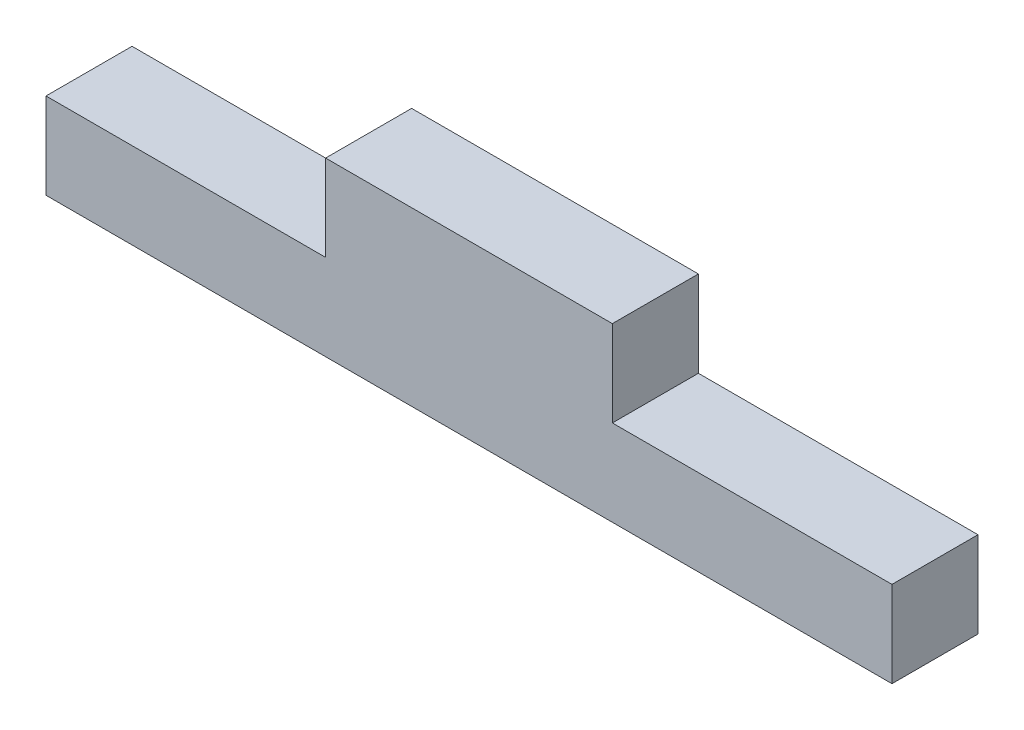
from build123d import *

# Parameters (mm, degrees)
RESSALTO_EXTRUS_O1_DEPTH = 6


with BuildPart() as part:
    # Esboço1 → Ressalto-extrusão1 (new body)
    with BuildSketch(Plane.XY):
        Polygon((19.5, 12), (19.5, 6), (0, 6), (0, 0), (59, 0), (59, 6), (39.5, 6), (39.5, 12), align=None)
    extrude(amount=RESSALTO_EXTRUS_O1_DEPTH)


solid = part.part
